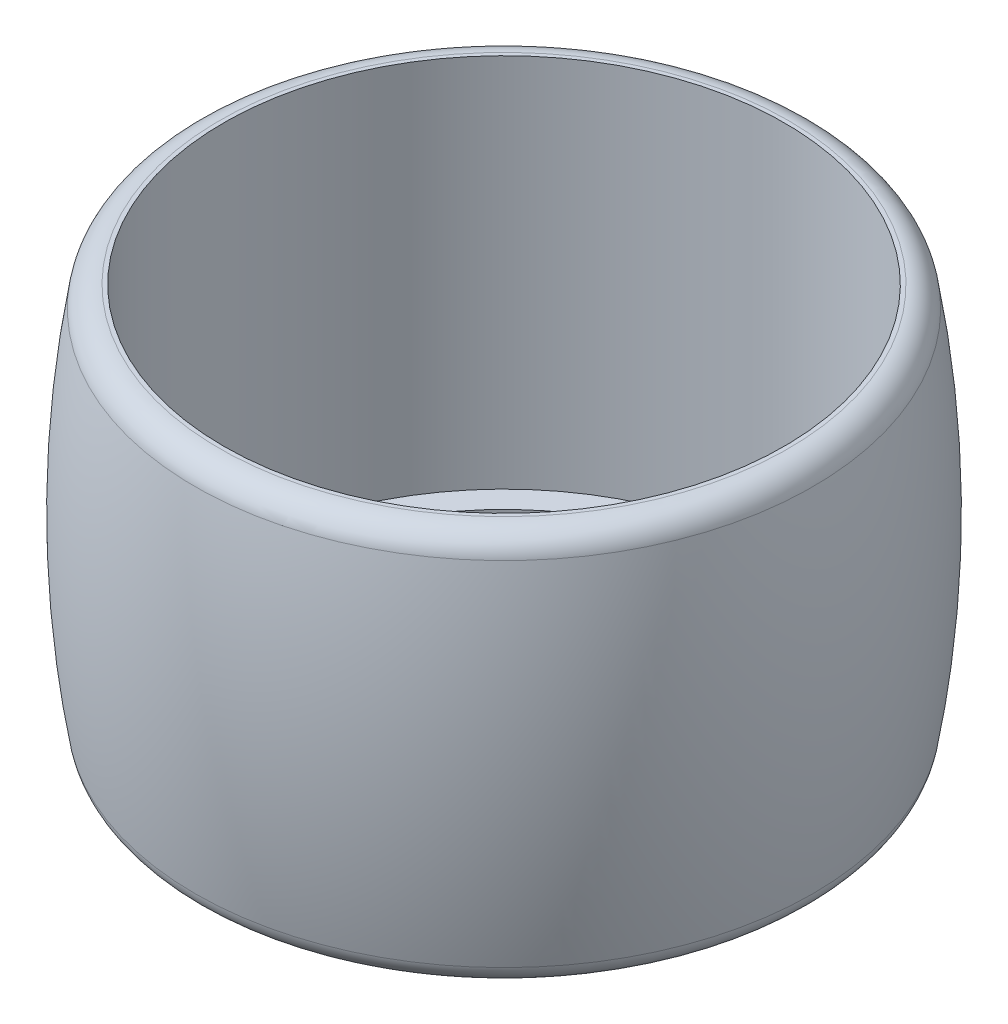
from build123d import *

# Parameters (mm, degrees)
FILLET1_R = 2


with BuildPart() as part:
    # Sketch1 → Revolve3 (revolve)
    with BuildSketch(Plane.XY, mode=Mode.PRIVATE) as revolve3_sk:
        with BuildLine():
            Line((20.55, -14.35), (22.55, -14.35))
            Line((22.55, -14.35), (22.55, 15.85))
            Line((22.55, 15.85), (24.55, 15.85))
            ThreePointArc((24.55, 15.85), (26.022816741, 0), (24.55, -15.85))
            Line((24.55, -15.85), (20.55, -15.85))
            Line((20.55, -15.85), (20.55, -14.35))
        make_face()
    revolve(revolve3_sk.sketch.rotate(Axis((0, 7.38603037, 0), (0, -1, 0)), 90), axis=Axis((0, 7.38603037, 0), (0, -1, 0)))

    # Fillet1
    fillet1_edges = [part.edges().sort_by_distance(p)[0] for p in [
        (0, -15.85, -24.55),
        (0, 15.85, -24.55),
    ]]
    fillet(fillet1_edges, radius=FILLET1_R)


solid = part.part
